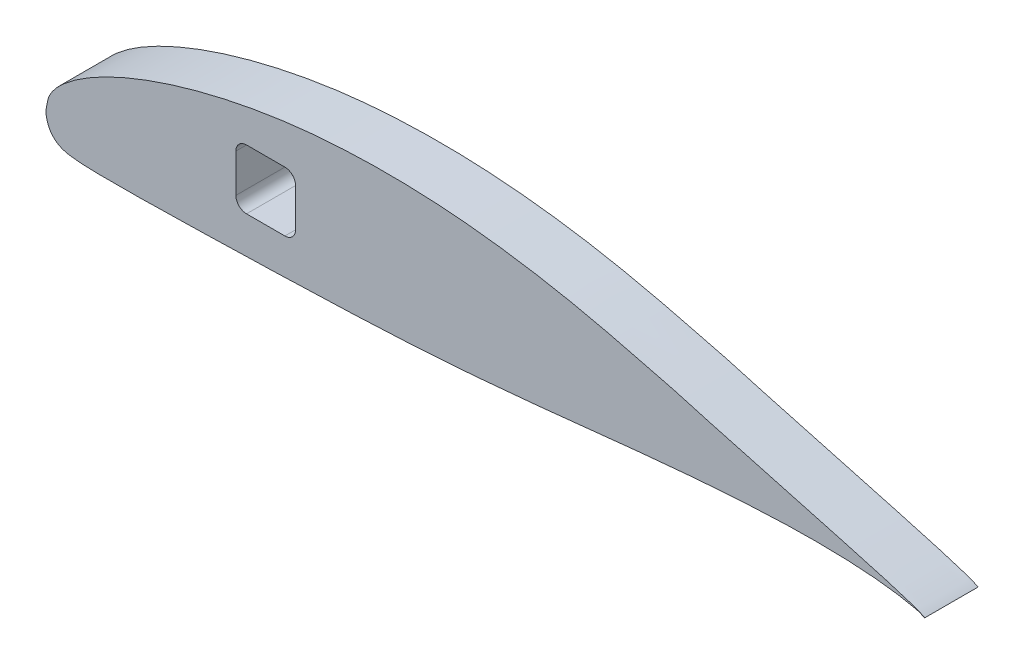
from build123d import *

# Parameters (mm, degrees)
BOSS_EXTRUDE2_DEPTH = 25.4


with BuildPart() as part:
    # Sketch4 → Boss-Extrude2 (new body)
    with BuildSketch(Plane.XY):
        with BuildLine():
            add(Edge.make_bspline(
                [(419.1, 0), (419.135582716, 0.03083172), (415.908005577, 1.680175529), (413.243760321, 2.454493251), (409.043286393, 3.883999291), (404.4480844, 5.264683523), (399.073048504, 6.846720853), (393.069943474, 8.553830714), (386.416537763, 10.41256237), (379.149346258, 12.415240197), (371.290373604, 14.566338653), (362.867607834, 16.860077141), (353.911264701, 19.297096421), (344.453150457, 21.873007185), (334.523432327, 24.569882466), (324.169303455, 27.421602194), (313.362731471, 30.249914273), (302.744262202, 33.575143193), (295.533701879, 35.246609467), (292.1, 36.089138265)],
                knots=[0, 0, 0, 0, 0.003263265, 0.007250558, 0.012051787, 0.017662333, 0.024068314, 0.031249696, 0.03918465, 0.047847638, 0.057210696, 0.067242333, 0.07790876, 0.089173985, 0.100998599, 0.113341295, 0.126157183, 0.139462308, 0.151635715, 0.151635715, 0.151635715, 0.151635715], degree=3))
            Line((292.1, 36.089138265), (292.1, 1.333976234))
            add(Edge.make_bspline(
                [(292.1, 1.333976234), (295.529208521, 1.66142382), (302.667549777, 2.322124521), (313.398970817, 3.229221233), (324.158839539, 4.033155247), (334.52141781, 4.684591363), (344.449906704, 5.179159417), (353.909457193, 5.50145283), (362.866468875, 5.68255661), (371.289861146, 5.661361852), (379.150044794, 5.507307551), (386.418012098, 5.19545299), (393.072269136, 4.746630095), (399.076807101, 4.179459259), (404.450455268, 3.489984039), (409.051278483, 2.783984412), (413.236952464, 1.837007232), (415.921101734, 1.371107043), (419.065830525, -0.029607174), (419.1, 0)],
                knots=[0.85342536, 0.85342536, 0.85342536, 0.85342536, 0.865287848, 0.878111787, 0.890511304, 0.902443005, 0.913865891, 0.924742046, 0.935035831, 0.944714495, 0.953747112, 0.962105881, 0.969765452, 0.97670305, 0.982898839, 0.988333206, 0.992993712, 0.996866343, 1, 1, 1, 1], degree=3))
        make_face()
        with BuildLine():
            Line((292.1, 1.333976234), (292.1, 36.089138265))
            add(Edge.make_bspline(
                [(292.1, 36.089138265), (291.712067661, 36.184325378), (287.400368227, 37.248919845), (279.147802785, 39.48983049), (267.187027603, 42.40924598), (255.03469047, 45.168428419), (242.72118539, 47.650209376), (230.296228944, 49.833894591), (217.801864375, 51.680006577), (205.284000487, 53.175668631), (192.786307767, 54.307105516), (180.352488326, 55.055153751), (168.027001927, 55.419018534), (155.853682434, 55.415704887), (143.87484882, 55.043188606), (132.132886758, 54.31287262), (120.66707402, 53.241130474), (109.522615964, 51.802214496), (98.737214119, 50.046324189), (88.347101396, 48.018984454), (78.388903375, 45.752295043), (68.897602741, 43.276072625), (59.906772527, 40.616983942), (51.447808112, 37.802843474), (43.549919517, 34.862025865), (36.241276719, 31.820931595), (29.547220551, 28.707908655), (23.489975501, 25.553233337), (18.091178224, 22.384144218), (13.365884381, 19.2305327), (9.330250208, 16.113817985), (5.969851951, 13.038999763), (3.345197754, 9.938584311), (1.180192797, 6.535708142), (0.479614476, 3.079908406), (-0.173094538, -0.266173519), (0.240253697, -3.332942929), (1.378230663, -6.423813499), (3.229176053, -9.150211891), (5.896039459, -11.320678389), (9.37076014, -12.591423064), (13.453435799, -13.208305962), (18.177942301, -13.543713588), (23.569117067, -13.71233198), (29.61826198, -13.823243233), (36.304218059, -13.633510343), (43.607365535, -13.749516921), (51.499077676, -13.570479283), (59.953218347, -13.425446573), (68.939511532, -13.223717363), (78.426543, -12.998167708), (88.380880035, -12.741679467), (98.76735409, -12.457031064), (109.549481724, -12.140459653), (120.689292625, -11.788758271), (132.147836589, -11.396110922), (143.884459541, -10.953513815), (155.858263106, -10.452803048), (168.02720614, -9.869990689), (180.347887973, -9.165777547), (192.776520036, -8.328984733), (205.269979931, -7.367125203), (217.783705172, -6.283597235), (230.273405672, -5.088105923), (242.69443158, -3.805728614), (255.003698462, -2.484737799), (267.159514579, -1.183928962), (279.11891019, 0.06085411), (287.411482757, 0.884854057), (291.712223024, 1.296948262), (292.1, 1.333976234)],
                knots=[0.151635715, 0.151635715, 0.151635715, 0.151635715, 0.15301104, 0.166927615, 0.181082, 0.19540448, 0.209838051, 0.224332605, 0.238841949, 0.253325073, 0.267739982, 0.282048685, 0.296212777, 0.310196043, 0.323962314, 0.337476235, 0.350702495, 0.363610632, 0.376163959, 0.388325705, 0.400058826, 0.41132739, 0.422098222, 0.43233946, 0.442020271, 0.451113163, 0.459592207, 0.467434959, 0.474622154, 0.48114013, 0.486983094, 0.492171114, 0.496782496, 0.500970226, 0.505871632, 0.508789423, 0.512670174, 0.516325668, 0.520069902, 0.523879651, 0.527960743, 0.532641784, 0.538069255, 0.544264221, 0.551214848, 0.558899645, 0.567291448, 0.576362099, 0.586079537, 0.596409112, 0.607314709, 0.618758332, 0.630699138, 0.643094929, 0.655903573, 0.669079202, 0.6825766, 0.696348373, 0.710348009, 0.724529116, 0.738844327, 0.753243365, 0.767678182, 0.782097111, 0.79644888, 0.810678263, 0.824728613, 0.838547559, 0.852083943, 0.85342536, 0.85342536, 0.85342536, 0.85342536], degree=3))
        make_face()
        with BuildLine():
            Line((95.631, 33.590938522), (113.919, 33.590938522))
            ThreePointArc((113.919, 33.590938522), (117.511102448, 32.10304097), (118.999, 28.510938522))
            Line((118.999, 28.510938522), (118.999, 10.222938522))
            ThreePointArc((118.999, 10.222938522), (117.511102448, 6.630836073), (113.919, 5.142938522))
            Line((113.919, 5.142938522), (95.631, 5.142938522))
            ThreePointArc((95.631, 5.142938522), (92.038897552, 6.630836073), (90.551, 10.222938522))
            Line((90.551, 10.222938522), (90.551, 28.510938522))
            ThreePointArc((90.551, 28.510938522), (92.038897552, 32.10304097), (95.631, 33.590938522))
        make_face(mode=Mode.SUBTRACT)
    extrude(amount=BOSS_EXTRUDE2_DEPTH)


solid = part.part
